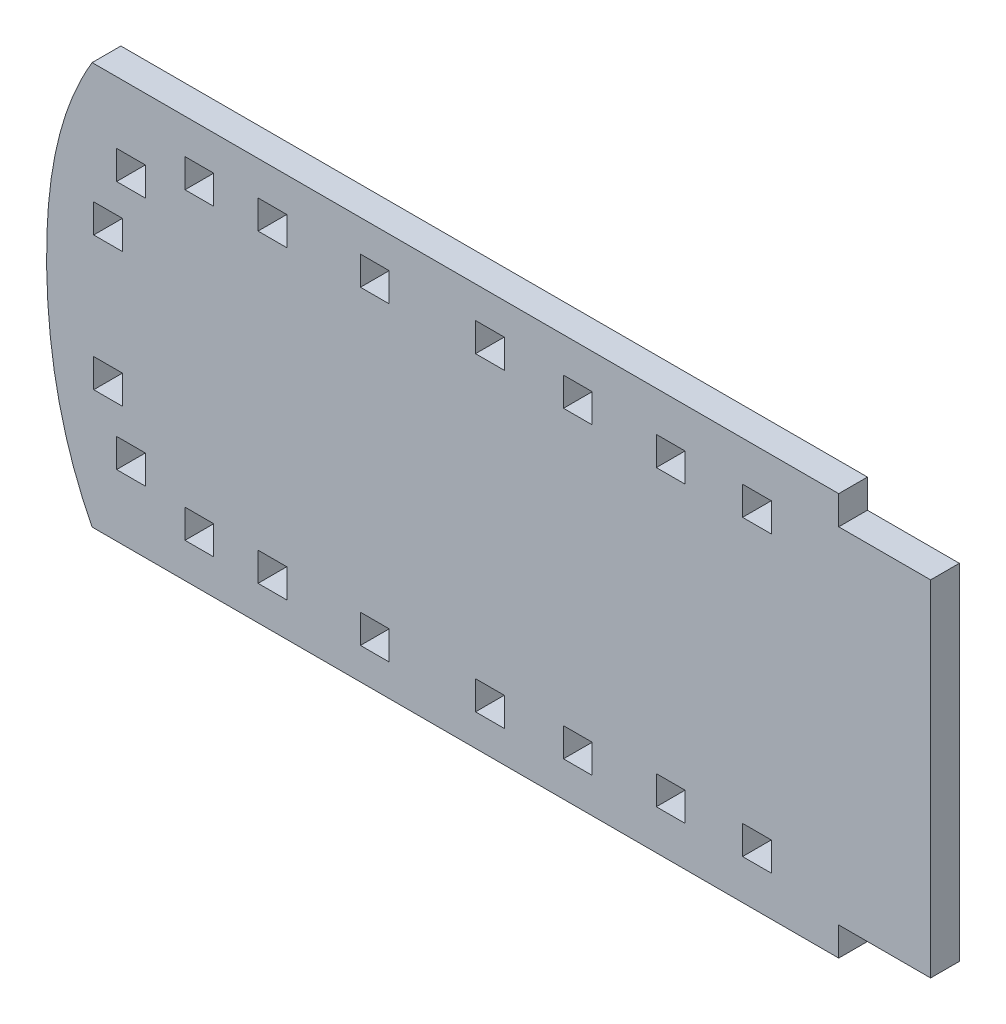
from build123d import *

# Parameters (mm, degrees)
BOSS_EXTRUDE1_DEPTH = 3.175
CUT_EXTRUDE1_DEPTH  = 3.175
SKETCH3_W           = 3.175
SKETCH3_H           = 3.175
CUT_EXTRUDE2_DEPTH  = 3.175


with BuildPart() as part:
    # Sketch1 → Boss-Extrude1 (new body)
    with BuildSketch(Plane.XY):
        with BuildLine():
            Line((133.353452848, 0), (218.438559169, 0))
            Line((218.438559169, 0), (218.438559169, -3.175))
            Line((218.438559169, -3.175), (228.593504491, -3.175))
            Line((228.593504491, -3.175), (228.593504491, -41.275))
            Line((228.593504491, -41.275), (218.438559169, -41.275))
            Line((218.438559169, -41.275), (218.438559169, -44.45))
            Line((218.438559169, -44.45), (133.353452848, -44.45))
            add(Edge.make_bspline(
                [(133.353452848, 0), (129.670007688, -3.804094497), (126.127807653, -11.460398689), (125.717598982, -27.472957947), (126.742796491, -38.641939676), (133.353452848, -44.45)],
                knots=[0, 0, 0, 0, 0.328355513, 0.50111915, 1, 1, 1, 1], degree=3))
        make_face()
    extrude(amount=BOSS_EXTRUDE1_DEPTH)

    # Sketch2 → Cut-Extrude1 (cut)
    with BuildSketch(Plane.XY.offset(3.175)):
        with BuildLine():
            Line((135.939264538, 0), (128.336629453, 5.186344239))
            Line((128.336629453, 5.186344239), (108.478299615, -42.096060539))
            Line((108.478299615, -42.096060539), (132.091652271, -56.370762285))
            Line((132.091652271, -56.370762285), (135.939264538, -44.45))
            add(Edge.make_bspline(
                [(135.939264538, 0), (131.854984435, -6.817127359), (129.691129791, -22.368396799), (132.428444631, -37.615693349), (135.939264538, -44.45)],
                knots=[0, 0, 0, 0, 0.506942817, 1, 1, 1, 1], degree=3))
        make_face()
    extrude(amount=-CUT_EXTRUDE1_DEPTH, mode=Mode.SUBTRACT)

    # Sketch3 → Cut-Extrude2 (cut)
    with BuildSketch(Plane.XY.offset(3.175)):
        with Locations((140.231064965, -8.443013353)):
            Rectangle(SKETCH3_W, SKETCH3_H)
        with Locations((155.86048705, -5.370418658)):
            Rectangle(SKETCH3_W, SKETCH3_H)
        with Locations((147.789651456, -5.451485607)):
            Rectangle(SKETCH3_W, SKETCH3_H)
        with Locations((167.178168731, -5.087390187)):
            Rectangle(SKETCH3_W, SKETCH3_H)
        with Locations((179.891954361, -5.087390187)):
            Rectangle(SKETCH3_W, SKETCH3_H)
        with Locations((189.613004004, -5.451485607)):
            Rectangle(SKETCH3_W, SKETCH3_H)
        with Locations((199.872722139, -5.995153624)):
            Rectangle(SKETCH3_W, SKETCH3_H)
        with Locations((209.401626696, -38.454846376)):
            Rectangle(SKETCH3_W, SKETCH3_H)
        with Locations((199.872722139, -38.454846376)):
            Rectangle(SKETCH3_W, SKETCH3_H)
        with Locations((189.613004004, -38.998514393)):
            Rectangle(SKETCH3_W, SKETCH3_H)
        with Locations((179.891954361, -39.362609813)):
            Rectangle(SKETCH3_W, SKETCH3_H)
        with Locations((167.178168731, -39.362609813)):
            Rectangle(SKETCH3_W, SKETCH3_H)
        with Locations((147.789651456, -38.998514393)):
            Rectangle(SKETCH3_W, SKETCH3_H)
        with Locations((155.86048705, -39.079581342)):
            Rectangle(SKETCH3_W, SKETCH3_H)
        with Locations((140.231064965, -36.006986647)):
            Rectangle(SKETCH3_W, SKETCH3_H)
        with Locations((137.703428064, -29.629038879)):
            Rectangle(SKETCH3_W, SKETCH3_H)
        with Locations((137.703428064, -14.820961121)):
            Rectangle(SKETCH3_W, SKETCH3_H)
        with Locations((209.401626696, -5.995153624)):
            Rectangle(SKETCH3_W, SKETCH3_H)
    extrude(amount=-CUT_EXTRUDE2_DEPTH, mode=Mode.SUBTRACT)


solid = part.part
